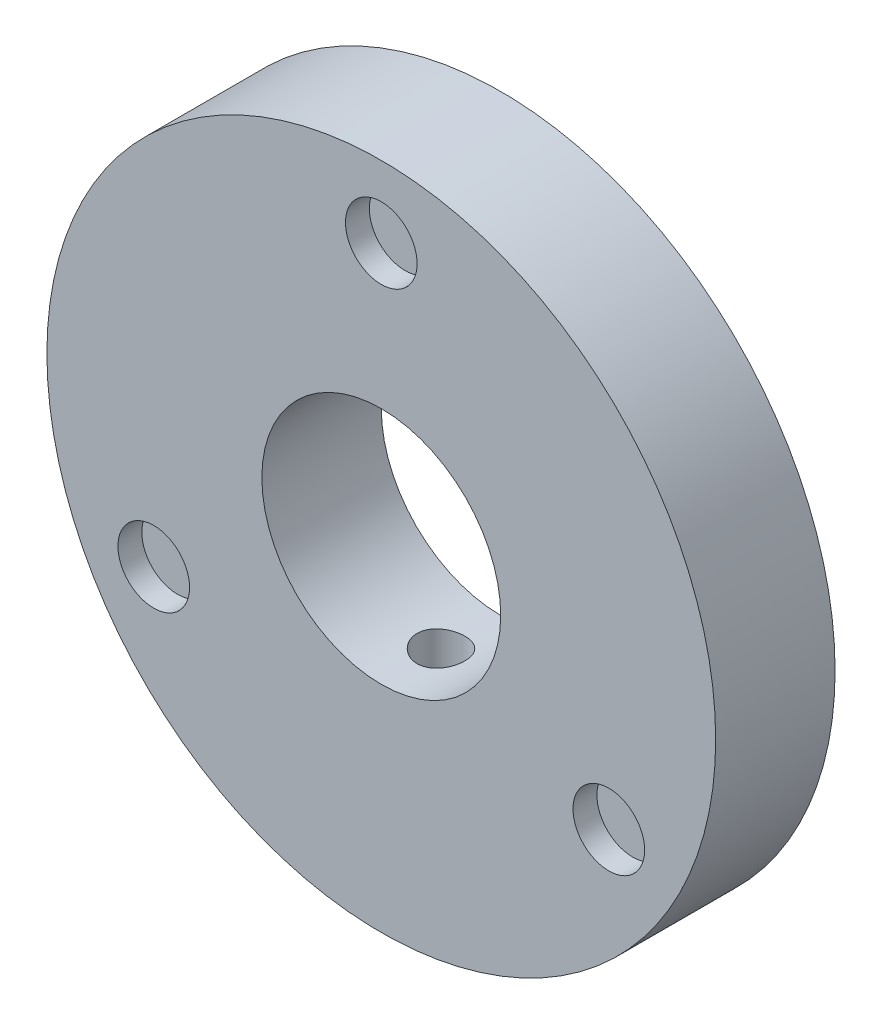
from build123d import *

# Parameters (mm, degrees)
SKETCH3_R           = 14
SKETCH3_R_2         = 5
BOSS_EXTRUDE1_DEPTH = 5
SKETCH4_R           = 1.5
CUT_EXTRUDE1_DEPTH  = 1
SKETCH5_R           = 1.5
CUT_EXTRUDE2_DEPTH  = 1
SKETCH6_R           = 1
CUT_EXTRUDE3_DEPTH  = 30


with BuildPart() as part:
    # Sketch3 → Boss-Extrude1 (new body)
    with BuildSketch(Plane.XY):
        Circle(SKETCH3_R)
        Circle(SKETCH3_R_2, mode=Mode.SUBTRACT)
    extrude(amount=BOSS_EXTRUDE1_DEPTH)

    # Sketch4 → Cut-Extrude1 (cut)
    with BuildSketch(Plane.XY.offset(5)):
        with Locations((0, 11)):
            Circle(SKETCH4_R)
        with Locations((9.526279442, -5.5)):
            Circle(SKETCH4_R)
        with Locations((-9.526279442, -5.5)):
            Circle(SKETCH4_R)
    extrude(amount=-CUT_EXTRUDE1_DEPTH, mode=Mode.SUBTRACT)

    # Sketch5 → Cut-Extrude2 (cut)
    with BuildSketch(Plane(origin=(0, 0, 0), x_dir=(-1, 0, 0), z_dir=(0, 0, -1))):
        with Locations((0, 11)):
            Circle(SKETCH5_R)
        with Locations((9.526279442, -5.5)):
            Circle(SKETCH5_R)
        with Locations((-9.526279442, -5.5)):
            Circle(SKETCH5_R)
    extrude(amount=-CUT_EXTRUDE2_DEPTH, mode=Mode.SUBTRACT)

    # Sketch6 → Cut-Extrude3 (cut)
    with BuildSketch(Plane(origin=(0, 0, 0), x_dir=(1, 0, 0), z_dir=(0, 1, 0))):
        with Locations((0, -2.5)):
            Circle(SKETCH6_R)
    extrude(amount=-CUT_EXTRUDE3_DEPTH, mode=Mode.SUBTRACT)


solid = part.part
